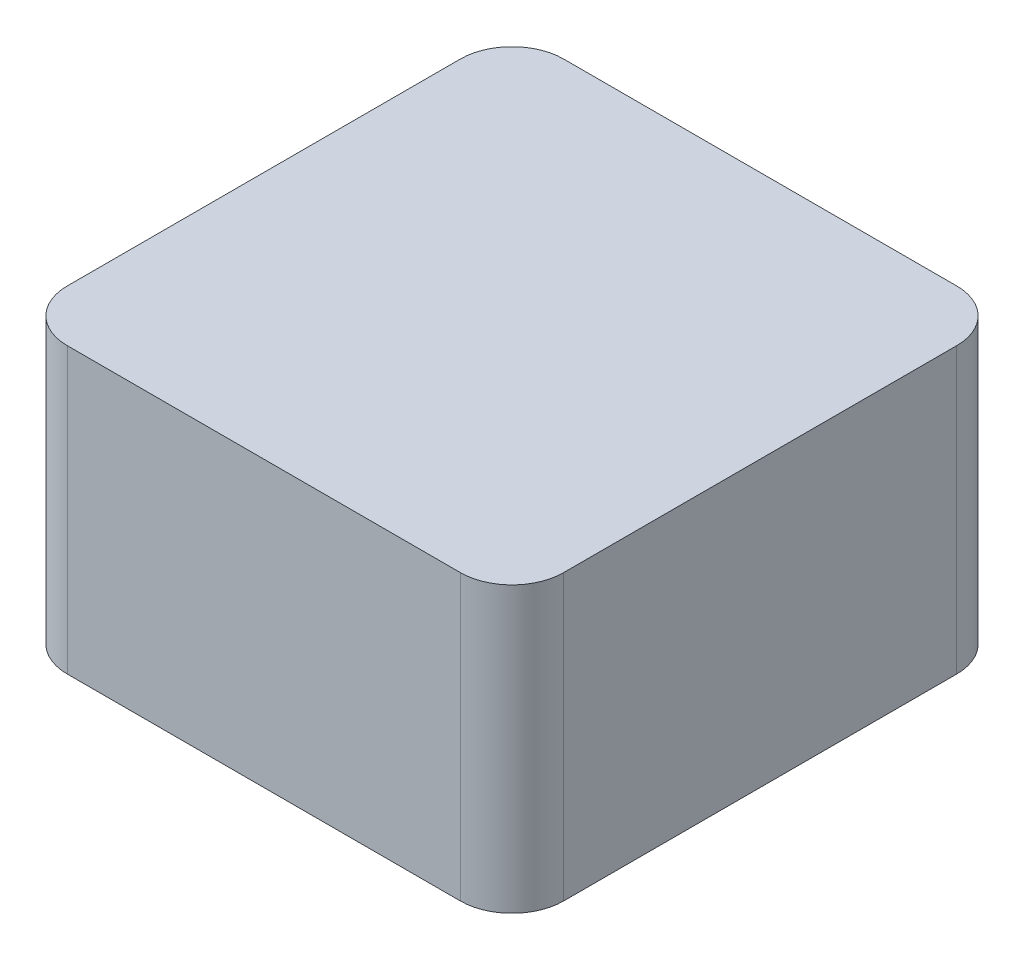
from build123d import *

# Parameters (mm, degrees)
SKETCH2_W           = 38.4
SKETCH2_H           = 38.4
BOSS_EXTRUDE1_DEPTH = 22
FILLET1_R           = 4


with BuildPart() as part:
    # Sketch2 → Boss-Extrude1 (new body)
    with BuildSketch(Plane(origin=(0, 0, 0), x_dir=(1, 0, 0), z_dir=(0, 1, 0))):
        with Locations((9.714743237, -9.243446602)):
            Rectangle(SKETCH2_W, SKETCH2_H)
    extrude(amount=BOSS_EXTRUDE1_DEPTH)

    # Fillet1
    fillet1_edges = [part.edges().sort_by_distance(p)[0] for p in [
        (-9.485256763, 11, -9.956553398),
        (28.914743237, 11, -9.956553398),
        (28.914743237, 11, 28.443446602),
        (-9.485256763, 11, 28.443446602),
    ]]
    fillet(fillet1_edges, radius=FILLET1_R)


solid = part.part
